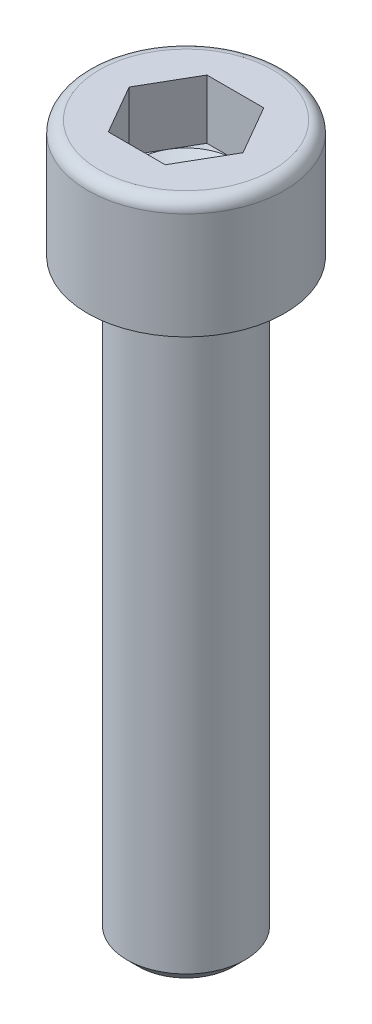
from build123d import *

# Parameters (mm, degrees)
ESQUISSE2_R             = 3
BASE_EXTRUSION_DEPTH    = 30
CHANFREIN1_SIZE         = 0.6
ENL_V_MAT_EXTRU_1_DEPTH = 3


with BuildPart() as part:
    # Esquisse2 → Base-Extrusion (new body)
    with BuildSketch(Plane(origin=(0, 0, 0), x_dir=(1, 0, 0), z_dir=(0, 1, 0))):
        with Locations(Location((0, 0, 0), (0, 0, 270))):  # turned: the seam where the file's is
            Circle(ESQUISSE2_R)
    extrude(amount=-BASE_EXTRUSION_DEPTH)

    # Chanfrein1
    chanfrein1_edges = [part.edges().sort_by_distance(p)[0] for p in [
        (0, -30, -3),
    ]]
    chamfer(chanfrein1_edges, length=CHANFREIN1_SIZE)

    # Esquisse5 → Boss.-Révol.1 (revolve)
    with BuildSketch(Plane.XY, mode=Mode.PRIVATE) as boss_r_vol_1_sk:
        with BuildLine():
            Line((2.5, 6), (2.5, 3))
            Line((2.5, 3), (0, 1.556624327))
            Line((0, 1.556624327), (0, 0))
            Line((0, 0), (5, 0))
            Line((5, 0), (5, 5.4))
            ThreePointArc((5, 5.4), (4.824264069, 5.824264069), (4.4, 6))
            Line((4.4, 6), (2.5, 6))
        make_face()
    revolve(boss_r_vol_1_sk.sketch.rotate(Axis((0, 6, 0), (0, -1, 0)), 90), axis=Axis((0, 6, 0), (0, -1, 0)))  # turned: the seam where the file's is

    # Esquisse7 → Enlèv. mat.-Extru.1 (cut)
    with BuildSketch(Plane(origin=(0, 6, 0), x_dir=(-1, 0, 0), z_dir=(0, 1, 0))):
        Polygon((1.443375673, 2.5), (-1.443375673, 2.5), (-2.886751346, 0), (-1.443375673, -2.5), (1.443375673, -2.5), (2.886751346, 0), align=None)
    extrude(amount=-ENL_V_MAT_EXTRU_1_DEPTH, mode=Mode.SUBTRACT)


solid = part.part
